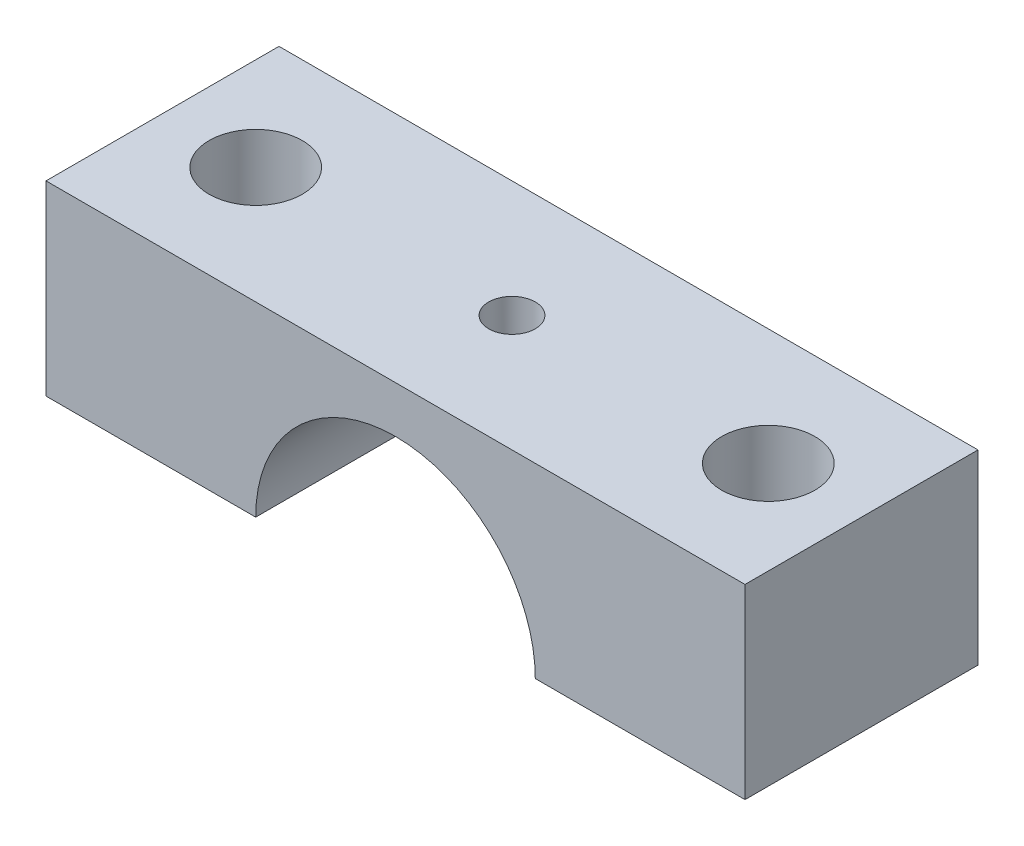
from build123d import *

# Parameters (mm, degrees)
SKETCH1_W               = 30
SKETCH1_H               = 10
SKETCH1_R               = 2
SKETCH1_R_2             = 1
BOSS_EXTRUDE1_DEPTH     = 8
SKETCH2_R               = 6
CUT_EXTRUDE1_DEPTH      = 6
CUT_EXTRUDE1_DEPTH_BACK = 6


with BuildPart() as part:
    # Sketch1 → Boss-Extrude1 (new body)
    with BuildSketch(Plane(origin=(0, 0, 0), x_dir=(1, 0, 0), z_dir=(0, 1, 0))):
        Rectangle(SKETCH1_W, SKETCH1_H)
        with Locations((-11, 0)):
            Circle(SKETCH1_R, mode=Mode.SUBTRACT)
        with Locations((11, 0)):
            Circle(SKETCH1_R, mode=Mode.SUBTRACT)
        Circle(SKETCH1_R_2, mode=Mode.SUBTRACT)
    extrude(amount=BOSS_EXTRUDE1_DEPTH)

    # Sketch2 → Cut-Extrude1 (cut, two sides)
    with BuildSketch(Plane.XY) as cut_extrude1_sk:
        Circle(SKETCH2_R)
    extrude(amount=CUT_EXTRUDE1_DEPTH, mode=Mode.SUBTRACT)
    extrude(cut_extrude1_sk.sketch, amount=-CUT_EXTRUDE1_DEPTH_BACK, mode=Mode.SUBTRACT)


solid = part.part
